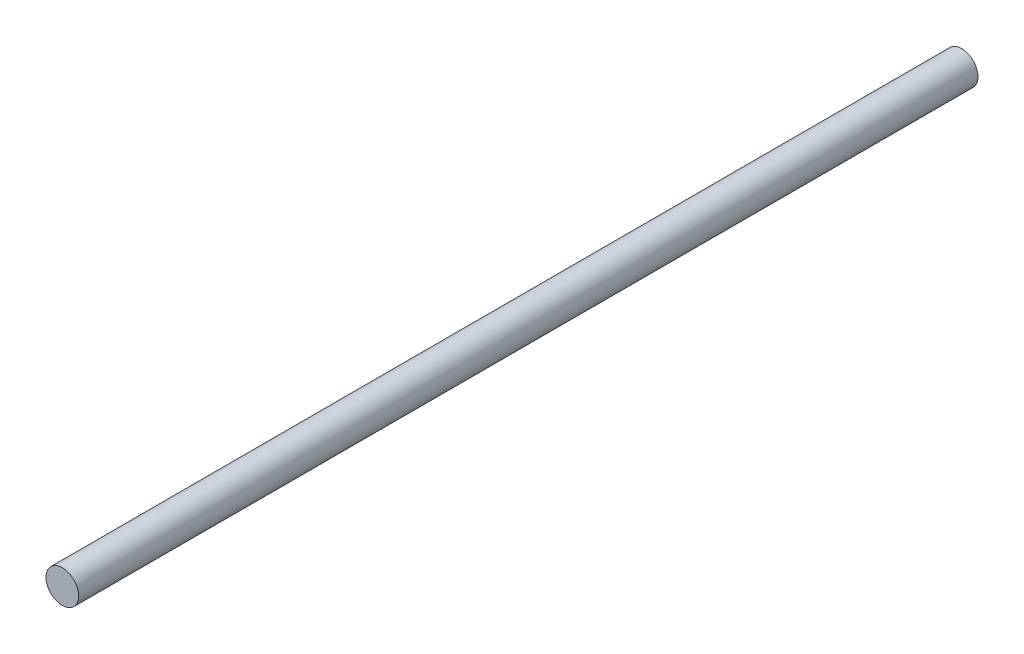
from build123d import *

# Parameters (mm, degrees)
SKETCH1_R           = 4
BOSS_EXTRUDE1_DEPTH = 220


with BuildPart() as part:
    # Sketch1 → Boss-Extrude1 (new body)
    with BuildSketch(Plane.XY):
        Circle(SKETCH1_R)
    extrude(amount=BOSS_EXTRUDE1_DEPTH)


solid = part.part
